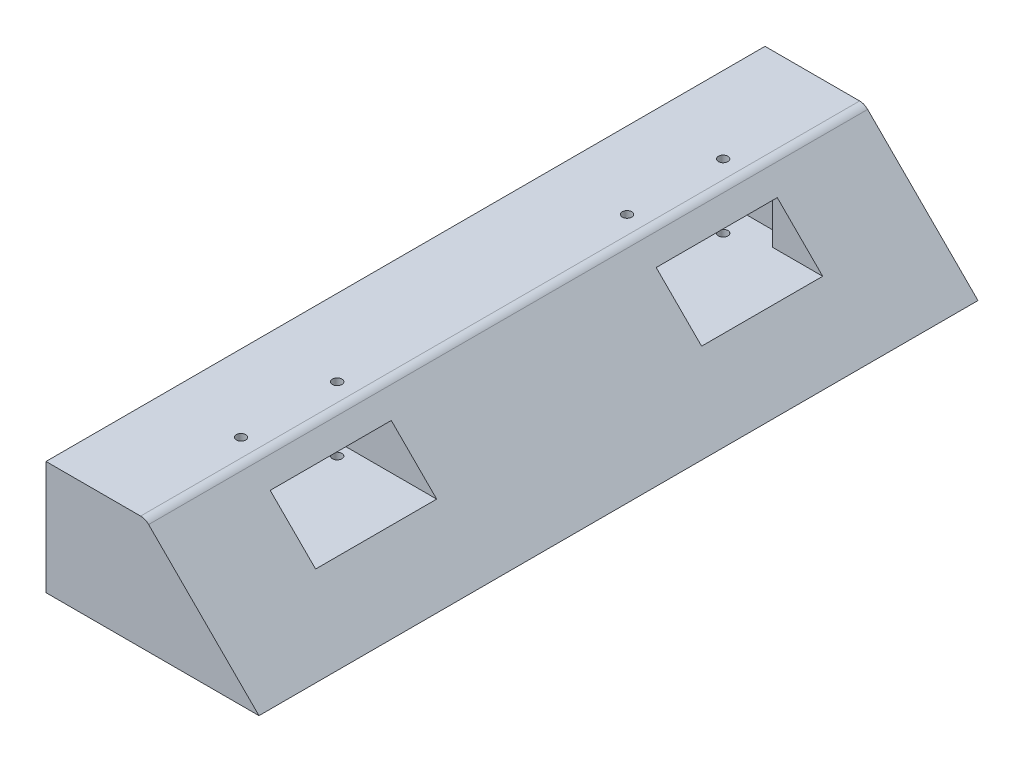
from build123d import *

# Parameters (mm, degrees)
SALIENTE_EXTRUIR1_DEPTH    = 190
CROQUIS3_W                 = 56.281965067
CROQUIS3_H                 = 32
CORTAR_EXTRUIR1_DEPTH      = 25.039324
CORTAR_EXTRUIR3_DEPTH      = 25.039324
SALIENTE_EXTRUIR2_REACH    = 62
SALIENTE_EXTRUIR3_REACH    = 132
CROQUIS7_W                 = 4
CROQUIS7_H                 = 12
CORTAR_EXTRUIR6_DEPTH      = 30
CROQUIS8_R                 = 1.25
CORTAR_EXTRUIR7_DEPTH      = 18
CORTAR_EXTRUIR7_DEPTH_BACK = 14.03932438
CROQUIS9_R                 = 3.5
CORTAR_EXTRUIR8_DEPTH      = 8


with BuildPart() as part:
    # Croquis1 → Saliente-Extruir1 (new body)
    with BuildSketch(Plane.XY):
        with BuildLine():
            Line((56.281965067, 0), (27.121320344, 29.160644724))
            ThreePointArc((27.121320344, 29.160644724), (26.148050297, 29.810962978), (25, 30.03932438))
            Line((25, 30.03932438), (0, 30.03932438))
            Line((0, 30.03932438), (0, 0))
            Line((0, 0), (56.281965067, 0))
        make_face()
    extrude(amount=SALIENTE_EXTRUIR1_DEPTH)

    # Croquis3 → Cortar-Extruir1 (cut)
    with BuildSketch(Plane.XZ):
        with Locations((28.140982534, 146)):
            Rectangle(CROQUIS3_W, CROQUIS3_H)
        with Locations((28.140982534, 44)):
            Rectangle(CROQUIS3_W, CROQUIS3_H)
    extrude(amount=-CORTAR_EXTRUIR1_DEPTH, mode=Mode.SUBTRACT)

    # Croquis4 → Cortar-Extruir3 (cut)
    with BuildSketch(Plane.XZ):
        Polygon((0, 130), (15, 130), (7.928932188, 122.928932188), (7.928932188, 67.071067812), (15, 60), (0, 60), align=None)
    extrude(amount=-CORTAR_EXTRUIR3_DEPTH, mode=Mode.SUBTRACT)

    # Croquis5 → Saliente-Extruir2 (add, up to next)
    with BuildSketch(Plane.XY.offset(130), mode=Mode.PRIVATE) as saliente_extruir2_sk1:
        Polygon((56.281965067, 0), (0, 0), (0, 13.03932438), (43.242640687, 13.03932438), align=None)
    saliente_extruir2_tool1 = extrude(saliente_extruir2_sk1.sketch, amount=SALIENTE_EXTRUIR2_REACH, mode=Mode.PRIVATE) - part.part
    add(saliente_extruir2_tool1.solids().sort_by_distance((25.023515, 6.234935, 130))[0])

    # Croquis6 → Saliente-Extruir3 (add, up to next)
    with BuildSketch(Plane(origin=(0, 0, 130), x_dir=(-1, 0, 0), z_dir=(0, 0, -1)), mode=Mode.PRIVATE) as saliente_extruir3_sk1:
        Polygon((0, 0), (0, 13.03932438), (-43.242640687, 13.03932438), (-56.281965067, 0), align=None)
    saliente_extruir3_tool1 = extrude(saliente_extruir3_sk1.sketch, amount=SALIENTE_EXTRUIR3_REACH, mode=Mode.PRIVATE) - part.part
    add(saliente_extruir3_tool1.solids().sort_by_distance((25.023515, 6.234935, 130))[0])

    # Croquis7 → Cortar-Extruir6 (cut)
    with BuildSketch(Plane.ZY):
        with Locations((26, 19.03932438)):
            Rectangle(CROQUIS7_W, CROQUIS7_H)
        with Locations((164, 19.03932438)):
            Rectangle(CROQUIS7_W, CROQUIS7_H)
    extrude(amount=-CORTAR_EXTRUIR6_DEPTH, mode=Mode.SUBTRACT)

    # Croquis8 → Cortar-Extruir7 (cut, two sides)
    with BuildSketch(Plane(origin=(0, 13.03932438, 0), x_dir=(1, 0, 0), z_dir=(0, 1, 0))) as cortar_extruir7_sk:
        with Locations((20.242640687, -158.7)):
            Circle(CROQUIS8_R)
        with Locations((20.242640687, -133.3)):
            Circle(CROQUIS8_R)
        with Locations((20.242640687, -31.3)):
            Circle(CROQUIS8_R)
        with Locations((20.242640687, -56.7)):
            Circle(CROQUIS8_R)
    extrude(amount=CORTAR_EXTRUIR7_DEPTH, mode=Mode.SUBTRACT)
    extrude(cortar_extruir7_sk.sketch, amount=-CORTAR_EXTRUIR7_DEPTH_BACK, mode=Mode.SUBTRACT)

    # Croquis9 → Cortar-Extruir8 (cut)
    with BuildSketch(Plane.XZ):
        with Locations((20.242640687, 158.7)):
            Circle(CROQUIS9_R)
        with Locations((20.242640687, 133.3)):
            Circle(CROQUIS9_R)
        with Locations((20.242640687, 56.7)):
            Circle(CROQUIS9_R)
        with Locations((20.242640687, 31.3)):
            Circle(CROQUIS9_R)
    extrude(amount=-CORTAR_EXTRUIR8_DEPTH, mode=Mode.SUBTRACT)


solid = part.part
